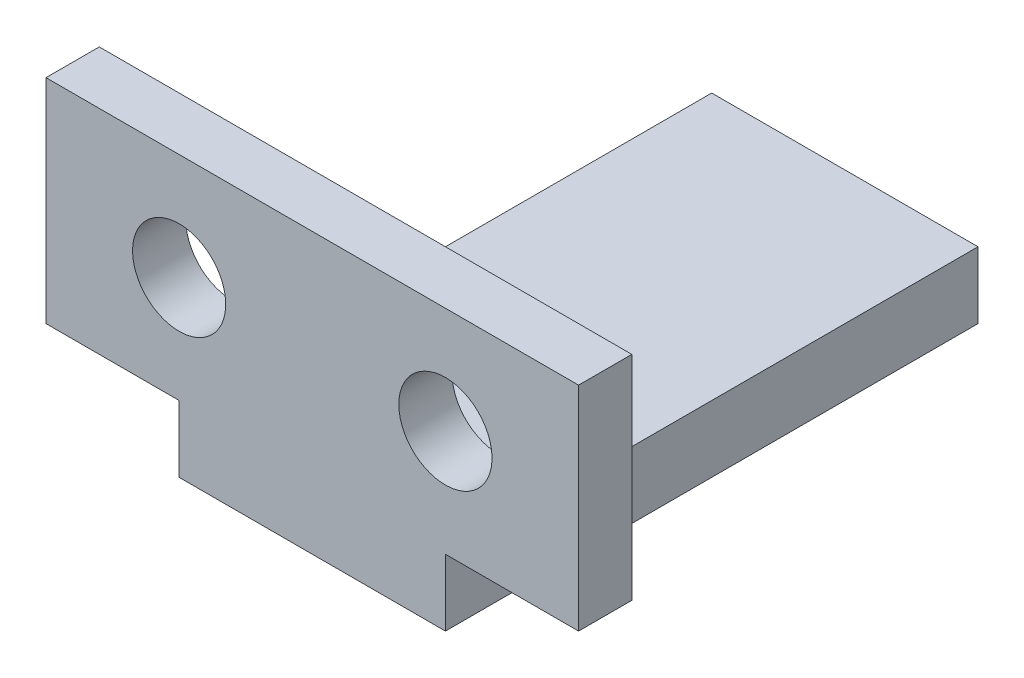
from build123d import *

# Parameters (mm, degrees)
SKETCH_1_W          = 20
SKETCH_1_H          = 8
EXTRUDE_1_DEPTH     = 2
SKETCH_2_W          = 10
SKETCH_2_H          = 2.5
EXTRUDE_2_DEPTH     = 20
SKETCH_3_R          = 1.75
CUT_EXTRUDE_1_DEPTH = 20


with BuildPart() as part:
    # 草图1 → 凸台-拉伸1 (new body)
    with BuildSketch(Plane.XY):
        with Locations((10, 4)):
            Rectangle(SKETCH_1_W, SKETCH_1_H)
    extrude(amount=EXTRUDE_1_DEPTH)

    # 草图2 → 凸台-拉伸2 (add)
    with BuildSketch(Plane.XY.offset(2)):
        with Locations((10, -1.25)):
            Rectangle(SKETCH_2_W, SKETCH_2_H)
    extrude(amount=-EXTRUDE_2_DEPTH)

    # 草图3 → 切除-拉伸1 (cut)
    with BuildSketch(Plane(origin=(0, 0, 0), x_dir=(-1, 0, 0), z_dir=(0, 0, -1))):
        with Locations((-15, 4)):
            Circle(SKETCH_3_R)
        with Locations((-5, 4)):
            Circle(SKETCH_3_R)
    extrude(amount=-CUT_EXTRUDE_1_DEPTH, mode=Mode.SUBTRACT)


solid = part.part
